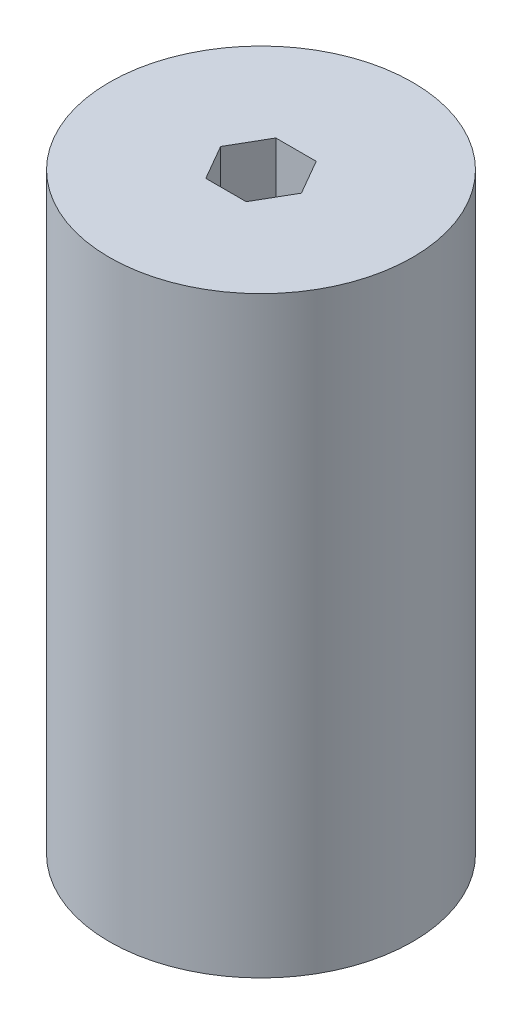
from build123d import *

# Parameters (mm, degrees)
SKETCH1_R           = 32.5
BOSS_EXTRUDE1_DEPTH = 127


with BuildPart() as part:
    # Sketch1 → Boss-Extrude1 (new body)
    with BuildSketch(Plane(origin=(0, 0, 0), x_dir=(1, 0, 0), z_dir=(0, 1, 0))):
        Circle(SKETCH1_R)
        Polygon((8.660254038, 0), (4.330127019, 7.5), (-4.330127019, 7.5), (-8.660254038, 0), (-4.330127019, -7.5), (4.330127019, -7.5), align=None, mode=Mode.SUBTRACT)
    extrude(amount=BOSS_EXTRUDE1_DEPTH)


solid = part.part
